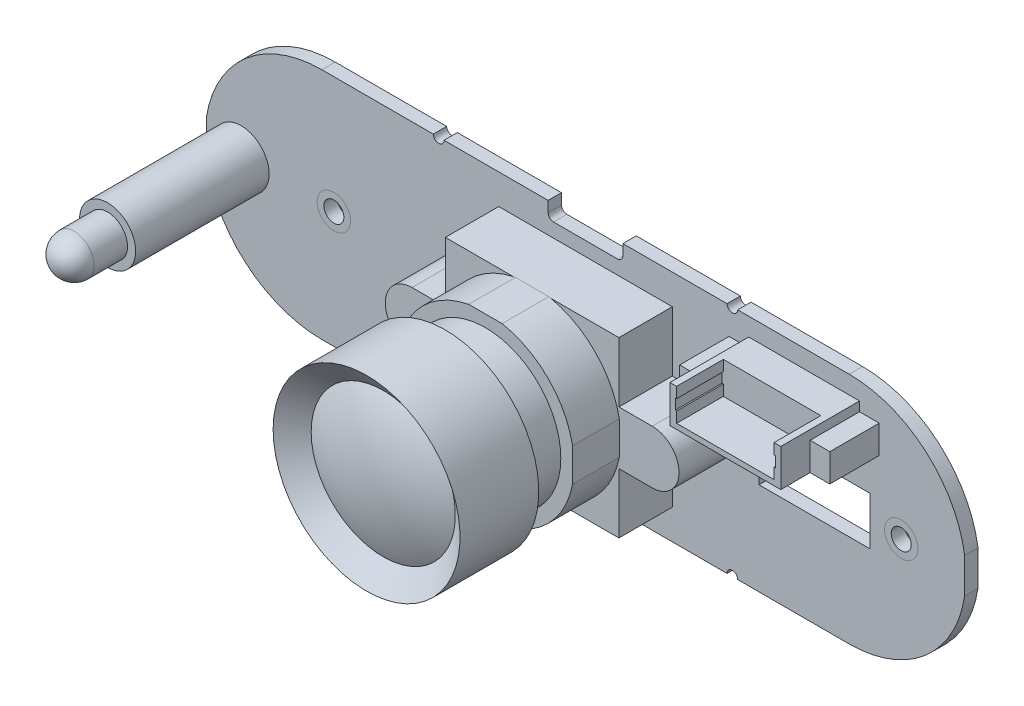
from build123d import *

# Parameters (mm, degrees)
BOSS_EXTRUDE1_DEPTH     = 0.5
SKETCH2_W               = 2
SKETCH2_H               = 10
CUT_EXTRUDE1_DEPTH      = 1.5
CUT_EXTRUDE1_DEPTH_BACK = 1.5
SKETCH3_R               = 0.75
SKETCH3_W               = 8.3
SKETCH3_H               = 3.6
CUT_EXTRUDE2_DEPTH      = 1.5
CUT_EXTRUDE2_DEPTH_BACK = 1.5
SKETCH4_R               = 2.1
BOSS_EXTRUDE2_DEPTH     = 10
SKETCH5_R               = 1.5
BOSS_EXTRUDE3_DEPTH     = 2.5
DOME1_FACE_RADIUS       = 1.5
DOME1_HEIGHT            = 1.5
SKETCH6_W               = 13
SKETCH6_H               = 4
SKETCH6_H_2             = 4.5
BOSS_EXTRUDE4_DEPTH     = 4
BOSS_EXTRUDE5_DEPTH     = 3.5
SKETCH8_R               = 5.65
BOSS_EXTRUDE6_DEPTH     = 3
BOSS_EXTRUDE7_DEPTH     = 3.7
SKETCH11_W              = 8.3
SKETCH11_H              = 2.8
BOSS_EXTRUDE8_DEPTH     = 2.2
CUT_EXTRUDE3_DEPTH      = 3.5
CUT_EXTRUDE4_REACH      = 3
SKETCH15_R              = 0.4


with BuildPart() as part:
    # Sketch1 → Boss-Extrude1 (new body, symmetric)
    with BuildSketch(Plane.XY):
        with BuildLine():
            Line((-19.75, 8.75), (19.75, 8.75))
            ThreePointArc((19.75, 8.75), (28.5, 0), (19.75, -8.75))
            Line((19.75, -8.75), (-19.75, -8.75))
            ThreePointArc((-19.75, -8.75), (-28.5, 0), (-19.75, 8.75))
        make_face()
    extrude(amount=BOSS_EXTRUDE1_DEPTH, both=True)

    # Sketch2 → Cut-Extrude1 (cut, two sides)
    with BuildSketch(Plane.XY) as cut_extrude1_sk:
        with Locations((29.4, 0)):
            Rectangle(SKETCH2_W, SKETCH2_H)
        with Locations((-29.4, 0)):
            Rectangle(SKETCH2_W, SKETCH2_H)
        with BuildLine():
            Line((2.4, 7.55), (-2.4, 7.55))
            ThreePointArc((-2.4, 7.55), (-2.682842712, 7.667157288), (-2.8, 7.95))
            Line((-2.8, 7.95), (-2.8, 9.95))
            Line((-2.8, 9.95), (2.8, 9.95))
            Line((2.8, 9.95), (2.8, 7.95))
            ThreePointArc((2.8, 7.95), (2.682842712, 7.667157288), (2.4, 7.55))
        make_face()
    extrude(amount=CUT_EXTRUDE1_DEPTH, mode=Mode.SUBTRACT)
    extrude(cut_extrude1_sk.sketch, amount=-CUT_EXTRUDE1_DEPTH_BACK, mode=Mode.SUBTRACT)

    # Sketch3 → Cut-Extrude2 (cut, two sides)
    with BuildSketch(Plane.XY) as cut_extrude2_sk:
        with Locations((23.65, 0)):
            Circle(SKETCH3_R)
        with Locations((-18.85, 0)):
            Circle(SKETCH3_R)
        with Locations((17.15, 0)):
            Rectangle(SKETCH3_W, SKETCH3_H)
    extrude(amount=CUT_EXTRUDE2_DEPTH, mode=Mode.SUBTRACT)
    extrude(cut_extrude2_sk.sketch, amount=-CUT_EXTRUDE2_DEPTH_BACK, mode=Mode.SUBTRACT)

    # Sketch4 → Boss-Extrude2 (add)
    with BuildSketch(Plane.XY.offset(0.5)):
        with Locations((-25.8, 0)):
            Circle(SKETCH4_R)
    extrude(amount=BOSS_EXTRUDE2_DEPTH)

    # Sketch5 → Boss-Extrude3 (add)
    with BuildSketch(Plane.XY.offset(10.5)):
        with Locations((-25.8, 0)):
            Circle(SKETCH5_R)
    extrude(amount=BOSS_EXTRUDE3_DEPTH)

    # Dome1: a dome of height H over a round flat face of radius A is a cap of a sphere of radius (A * A + H * H) / (2 * H)
    dome1_r = (DOME1_FACE_RADIUS * DOME1_FACE_RADIUS + DOME1_HEIGHT * DOME1_HEIGHT) / (2 * DOME1_HEIGHT)
    dome1_base = Plane((-25.8, 0, 13), z_dir=(0, 0, 1))
    with Locations(dome1_base.offset(DOME1_HEIGHT - dome1_r)):
        dome1_ball = Sphere(dome1_r, mode=Mode.PRIVATE)
    add(split(dome1_ball, bisect_by=dome1_base, keep=Keep.TOP, mode=Mode.PRIVATE))

    # Sketch6 → Boss-Extrude4 (add)
    with BuildSketch(Plane.XY.offset(0.5)):
        with BuildLine():
            Line((-6.5, -2), (-6.5, 2))
            Line((-6.5, 2), (-9, 2))
            ThreePointArc((-9, 2), (-11, 0), (-9, -2))
            Line((-9, -2), (-6.5, -2))
        make_face()
        Rectangle(SKETCH6_W, SKETCH6_H)
        with BuildLine():
            Line((9, 2), (6.5, 2))
            Line((6.5, 2), (6.5, -2))
            Line((6.5, -2), (9, -2))
            ThreePointArc((9, -2), (11, 0), (9, 2))
        make_face()
        with Locations((0, -4.25)):
            Rectangle(SKETCH6_W, SKETCH6_H_2)
        with Locations((0, 4.25)):
            Rectangle(SKETCH6_W, SKETCH6_H_2)
    extrude(amount=BOSS_EXTRUDE4_DEPTH)

    # Sketch7 → Boss-Extrude5 (add)
    with BuildSketch(Plane.XY.offset(4.5)):
        with BuildLine():
            Line((6.531462317, 1.25), (6.531462317, -1.25))
            ThreePointArc((6.531462317, -1.25), (4.702260095, -4.702260095), (1.25, -6.531462317))
            Line((1.25, -6.531462317), (-1.25, -6.531462317))
            ThreePointArc((-1.25, -6.531462317), (-4.702260095, -4.702260095), (-6.531462317, -1.25))
            Line((-6.531462317, -1.25), (-6.531462317, 1.25))
            ThreePointArc((-6.531462317, 1.25), (-4.702260095, 4.702260095), (-1.25, 6.531462317))
            Line((-1.25, 6.531462317), (1.25, 6.531462317))
            ThreePointArc((1.25, 6.531462317), (4.702260095, 4.702260095), (6.531462317, 1.25))
        make_face()
    extrude(amount=BOSS_EXTRUDE5_DEPTH)

    # Sketch8 → Boss-Extrude6 (add)
    with BuildSketch(Plane.XY.offset(8)):
        Circle(SKETCH8_R)
    extrude(amount=BOSS_EXTRUDE6_DEPTH)

    # Sketch9 → Revolve1 (revolve)
    with BuildSketch(Plane(origin=(0, 0, 0), x_dir=(1, 0, 0), z_dir=(0, 1, 0))):
        with BuildLine():
            Line((0, -11), (7, -11))
            Line((7, -11), (7, -16.9))
            Line((7, -16.9), (5.4, -15.65))
            ThreePointArc((5.4, -15.65), (2.771394054, -16.583422311), (0, -16.9))
            Line((0, -16.9), (0, -11))
        make_face()
    revolve(axis=Axis((0, 0, 0.5), (0, 0, 1)))

    # Sketch10 → Boss-Extrude7 (add)
    with BuildSketch(Plane.XY.offset(0.5)):
        Polygon((10.75, 4.6), (22, 4.6), (22, 6.7), (20.525, 6.7), (20.525, 7.4), (12.225, 7.4), (12.225, 6.7), (10.75, 6.7), align=None)
    extrude(amount=BOSS_EXTRUDE7_DEPTH)

    # Sketch11 → Boss-Extrude8 (add)
    with BuildSketch(Plane.XY.offset(4.2)):
        with Locations((16.375, 6)):
            Rectangle(SKETCH11_W, SKETCH11_H)
    extrude(amount=BOSS_EXTRUDE8_DEPTH)

    # Sketch12 → Cut-Extrude3 (cut)
    with BuildSketch(Plane.XY.offset(6.4)):
        Polygon((20.025, 7.4), (20.025, 6.6), (20.125, 6.6), (20.125, 5.8), (20.025, 5.8), (20.025, 5), (12.725, 5), (12.725, 5.8), (12.625, 5.8), (12.625, 6.6), (12.725, 6.6), (12.725, 7.4), align=None)
    extrude(amount=-CUT_EXTRUDE3_DEPTH, mode=Mode.SUBTRACT)

    # Sketch15 → Cut-Extrude4 (cut, up to next)
    with BuildSketch(Plane.XY.offset(0.5), mode=Mode.PRIVATE) as cut_extrude4_sk1:
        with Locations((11, 8.75)):
            Circle(SKETCH15_R)
    cut_extrude4_tool1 = extrude(cut_extrude4_sk1.sketch, amount=-CUT_EXTRUDE4_REACH, mode=Mode.PRIVATE) & part.part
    add(cut_extrude4_tool1.solids().sort_by_distance((11, 8.75, 0.5))[0], mode=Mode.SUBTRACT)
    # Sketch15 → Cut-Extrude4 (cut, up to next)
    with BuildSketch(Plane.XY.offset(0.5), mode=Mode.PRIVATE) as cut_extrude4_sk2:
        with Locations((-11, 8.75)):
            Circle(SKETCH15_R)
    cut_extrude4_tool2 = extrude(cut_extrude4_sk2.sketch, amount=-CUT_EXTRUDE4_REACH, mode=Mode.PRIVATE) & part.part
    add(cut_extrude4_tool2.solids().sort_by_distance((-11, 8.75, 0.5))[0], mode=Mode.SUBTRACT)
    # Sketch15 → Cut-Extrude4 (cut, up to next)
    with BuildSketch(Plane.XY.offset(0.5), mode=Mode.PRIVATE) as cut_extrude4_sk3:
        with Locations((-11, -8.75)):
            Circle(SKETCH15_R)
    cut_extrude4_tool3 = extrude(cut_extrude4_sk3.sketch, amount=-CUT_EXTRUDE4_REACH, mode=Mode.PRIVATE) & part.part
    add(cut_extrude4_tool3.solids().sort_by_distance((-11, -8.75, 0.5))[0], mode=Mode.SUBTRACT)
    # Sketch15 → Cut-Extrude4 (cut, up to next)
    with BuildSketch(Plane.XY.offset(0.5), mode=Mode.PRIVATE) as cut_extrude4_sk4:
        with Locations((11, -8.75)):
            Circle(SKETCH15_R)
    cut_extrude4_tool4 = extrude(cut_extrude4_sk4.sketch, amount=-CUT_EXTRUDE4_REACH, mode=Mode.PRIVATE) & part.part
    add(cut_extrude4_tool4.solids().sort_by_distance((11, -8.75, 0.5))[0], mode=Mode.SUBTRACT)


solid = part.part
